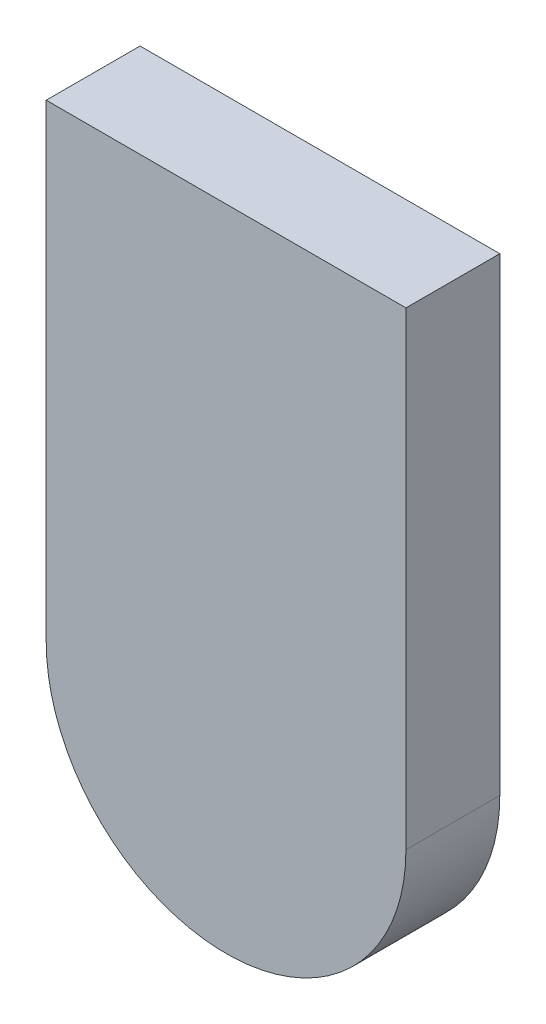
from build123d import *

# Parameters (mm, degrees)
BOSS_EXTRUDE1_DEPTH = 6


with BuildPart() as part:
    # Sketch1 → Boss-Extrude1 (new body)
    with BuildSketch(Plane.XY):
        with BuildLine():
            Line((-11.5, 30), (11.5, 30))
            Line((11.5, 30), (11.5, 0))
            ThreePointArc((11.5, 0), (0, -11.5), (-11.5, 0))
            Line((-11.5, 0), (-11.5, 30))
        make_face()
    extrude(amount=BOSS_EXTRUDE1_DEPTH)


solid = part.part
